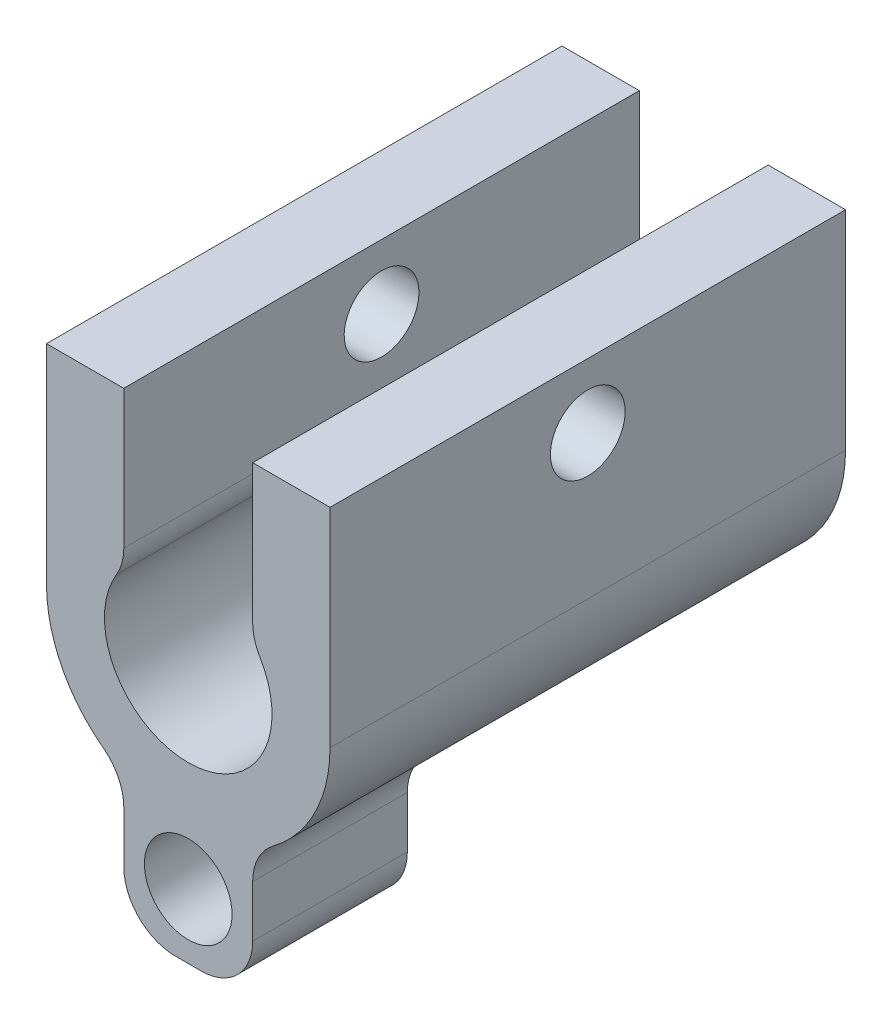
from build123d import *

# Parameters (mm, degrees)
BOSS_EXTRU_1_DEPTH      = 20
D_GAGEMENT_M2_51_D      = 2.9
ENL_V_MAT_EXTRU_1_DEPTH = 14
D_GAGEMENT_M31_D        = 3.4
CONG_1_R                = 2


with BuildPart() as part:
    # Esquisse1 → Boss.-Extru.1 (new body)
    with BuildSketch(Plane.XY):
        with BuildLine():
            Line((-5.5, 0), (-5.5, 8.076655966))
            Line((-5.5, 8.076655966), (-2.5, 8.076655966))
            Line((-2.5, 8.076655966), (-2.5, 2.076655966))
            ThreePointArc((-2.5, 2.076655966), (0, -3.25), (2.5, 2.076655966))
            Line((2.5, 2.076655966), (2.5, 8.076655966))
            Line((2.5, 8.076655966), (5.5, 8.076655966))
            Line((5.5, 8.076655966), (5.5, 0))
            ThreePointArc((5.5, 0), (4.91934955, -2.459674775), (3.3, -4.4))
            ThreePointArc((3.3, -4.4), (2.711145618, -5.105572809), (2.5, -6))
            Line((2.5, -6), (2.5, -8))
            ThreePointArc((2.5, -8), (1.914213562, -9.414213562), (0.5, -10))
            Line((0.5, -10), (-0.5, -10))
            ThreePointArc((-0.5, -10), (-1.914213562, -9.414213562), (-2.5, -8))
            Line((-2.5, -8), (-2.5, -6))
            ThreePointArc((-2.5, -6), (-2.711145618, -5.105572809), (-3.3, -4.4))
            ThreePointArc((-3.3, -4.4), (-4.91934955, -2.459674775), (-5.5, 0))
        make_face()
    extrude(amount=BOSS_EXTRU_1_DEPTH)

    # Dégagement M2.51 (through all)
    with Locations(Plane(origin=(5.5, 0, 0), x_dir=(0, 0, -1), z_dir=(1, 0, 0))):
        with Locations((-10, 5.576655966)):
            Hole(D_GAGEMENT_M2_51_D / 2)

    # Esquisse5 → Enlèv. mat.-Extru.1 (cut)
    with BuildSketch(Plane(origin=(0, 0, 0), x_dir=(-1, 0, 0), z_dir=(0, 0, -1))):
        with BuildLine():
            Line((-2.5, -6), (-2.5, -8))
            ThreePointArc((-2.5, -8), (-1.914213562, -9.414213562), (-0.5, -10))
            Line((-0.5, -10), (0.5, -10))
            ThreePointArc((0.5, -10), (1.914213562, -9.414213562), (2.5, -8))
            Line((2.5, -8), (2.5, -6))
            ThreePointArc((2.5, -6), (2.711145618, -5.105572809), (3.3, -4.4))
            Line((3.3, -4.4), (-3.3, -4.4))
            ThreePointArc((-3.3, -4.4), (-2.711145618, -5.105572809), (-2.5, -6))
        make_face()
    extrude(amount=-ENL_V_MAT_EXTRU_1_DEPTH, mode=Mode.SUBTRACT)

    # Dégagement M31 (through all)
    with Locations(Plane(origin=(0, -7.5, 20), x_dir=(1, 0, 0), z_dir=(0, 0, 1))):
        with Locations((0, 0)):
            Hole(D_GAGEMENT_M31_D / 2)

    # Congé1
    cong_1_edges = [part.edges().sort_by_distance(p)[0] for p in [
        (-2.5, 2.076655966, 10),
        (2.5, 2.076655966, 10),
    ]]
    fillet(cong_1_edges, radius=CONG_1_R)


solid = part.part
